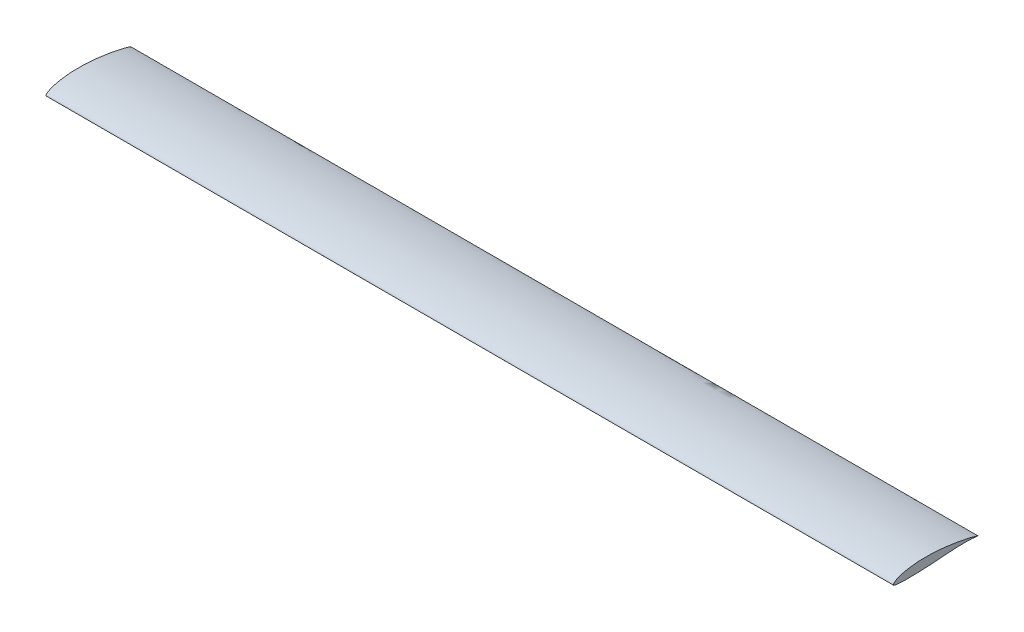
from build123d import *

# Parameters (mm, degrees)
BOSS_EXTRUDE1_DEPTH = 100


with BuildPart() as part:
    # Sketch1 → Boss-Extrude1 (new body)
    with BuildSketch(Plane(origin=(0, 0, 0), x_dir=(0, 0, -1), z_dir=(1, 0, 0))):
        with BuildLine():
            add(Edge.make_bspline(
                [(10, 0), (9.999939419, 0.000713132), (9.931657133, 0.020296402), (9.865845652, 0.045806616), (9.713370732, 0.098461344), (9.529934496, 0.155440178), (9.293258869, 0.218603649), (9.01508352, 0.287099471), (8.695827492, 0.36102207), (8.340942082, 0.43769333), (7.953735436, 0.513471695), (7.538041551, 0.586629562), (7.098068971, 0.656388808), (6.638907056, 0.722531419), (6.165958557, 0.782926954), (5.684675088, 0.836187714), (5.199937915, 0.879415237), (4.71629954, 0.911307468), (4.237937605, 0.930246437), (3.768871947, 0.935594449), (3.312900558, 0.926767535), (2.873614073, 0.903714805), (2.454462981, 0.86721996), (2.058929888, 0.817843427), (1.690267454, 0.757404767), (1.351716138, 0.687055298), (1.046257835, 0.60834613), (0.776384475, 0.523373057), (0.544671566, 0.433317228), (0.352222267, 0.340782127), (0.201446652, 0.248013088), (0.090021503, 0.157191328), (0.024627487, 0.075651156), (-0.013210507, -0.007418082), (0.04342594, -0.08032133), (0.148019106, -0.114655335), (0.298411848, -0.154423122), (0.50197863, -0.18209697), (0.754724851, -0.204011204), (1.055533574, -0.218063094), (1.401258269, -0.224872078), (1.788351726, -0.225405077), (2.21254414, -0.219892262), (2.668894662, -0.20906592), (3.151941089, -0.193182014), (3.65581937, -0.172704407), (4.175305117, -0.146536268), (4.706701885, -0.110887509), (5.247082717, -0.067630797), (5.792608401, -0.023977338), (6.336549917, 0.01616236), (6.870772921, 0.05026314), (7.386883, 0.076634755), (7.87667775, 0.093417535), (8.331771913, 0.100905324), (8.74489496, 0.098723644), (9.107165293, 0.088726635), (9.416420138, 0.070916203), (9.653610181, 0.051127952), (9.845670958, 0.02485104), (9.924118228, 0.015168355), (10.000062844, -0.000739778), (10, 0)],
                knots=[0, 0, 0, 0, 0.001701606, 0.006531267, 0.013928095, 0.023589153, 0.035531725, 0.049689132, 0.065834193, 0.083714751, 0.103116065, 0.123878752, 0.145814209, 0.168656186, 0.192131249, 0.215962296, 0.239896617, 0.26372889, 0.287268529, 0.31032554, 0.332738256, 0.354357712, 0.375035601, 0.394628911, 0.412991171, 0.429987473, 0.445487223, 0.459384642, 0.471588612, 0.48204456, 0.490731557, 0.497663076, 0.502883531, 0.506484353, 0.509678408, 0.514915306, 0.522533048, 0.532593992, 0.545061776, 0.559871774, 0.576884262, 0.595937966, 0.616822522, 0.639300677, 0.663099709, 0.687931905, 0.713498099, 0.739627386, 0.766289765, 0.793259505, 0.820148505, 0.846537949, 0.87201913, 0.896182354, 0.918637466, 0.938996033, 0.956919689, 0.972084766, 0.984184443, 0.992950329, 0.998234813, 1, 1, 1, 1], degree=3))
        make_face()
    extrude(amount=BOSS_EXTRUDE1_DEPTH)


solid = part.part
